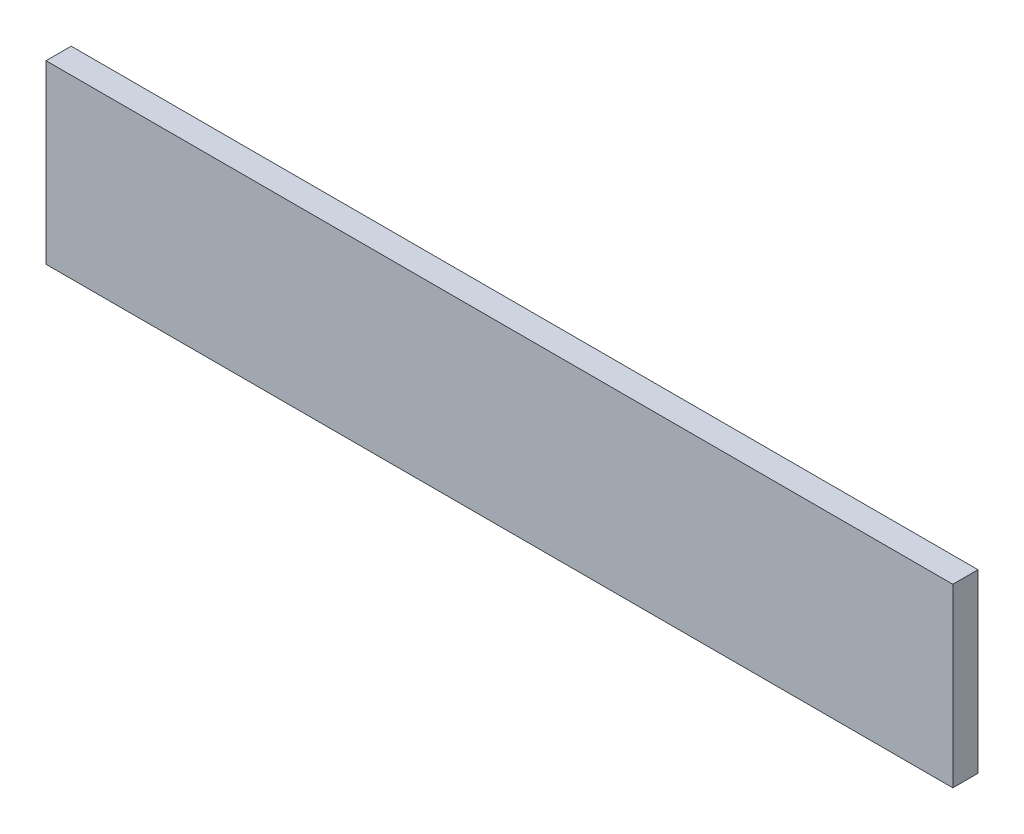
from build123d import *

# Parameters (mm, degrees)
CROQUIS1_W              = 180
CROQUIS1_H              = 35
SALIENTE_EXTRUIR1_DEPTH = 5


with BuildPart() as part:
    # Croquis1 → Saliente-Extruir1 (new body)
    with BuildSketch(Plane.XY):
        with Locations((90, 17.5)):
            Rectangle(CROQUIS1_W, CROQUIS1_H)
    extrude(amount=SALIENTE_EXTRUIR1_DEPTH)


solid = part.part
